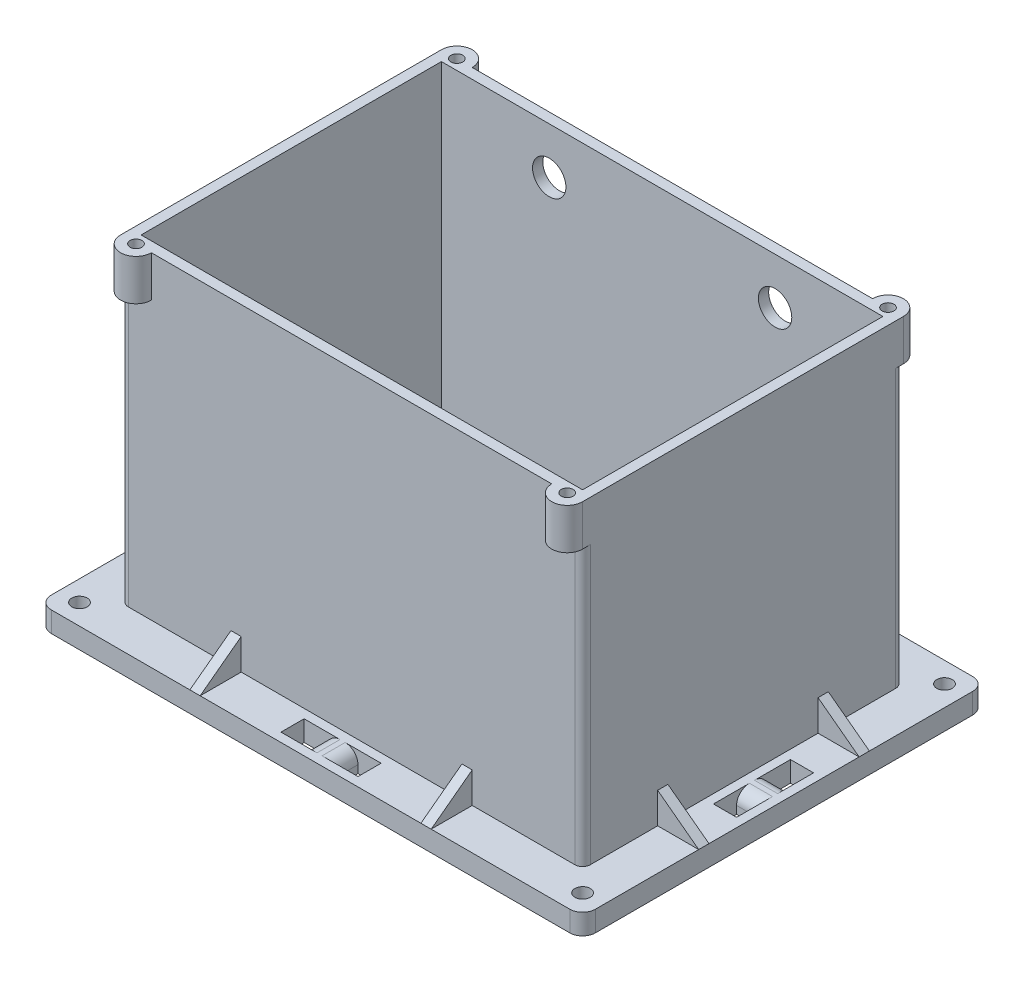
from build123d import *

# Parameters (mm, degrees)
BASE_W                                       = 90
BASE_H                                       = 62.5
BASE_EXTRUDE_DEPTH                           = 2
WALLS_W                                      = 90
WALLS_H                                      = 62.5
WALLS_W_2                                    = 86
WALLS_H_2                                    = 58.5
WALLS_EXTRUDE_DEPTH                          = 64
OUTJUT_EXTRUDE_DEPTH                         = 8
HOLES_R                                      = 1.15
HOLES_CUT_DEPTH                              = 6
ANTENNA_GPS_HOLES_R                          = 3.25
ANTENNA_GPS_HOLES_CUT_DEPTH                  = 2
PAD_W                                        = 106
PAD_H                                        = 78.5
PAD_EXTRUDE_DEPTH                            = 4
SCREW_HOLES_R                                = 1.5
SCREW_HOLES_CUT_DEPTH                        = 5
WALL_FILLETS_R                               = 1.5
LENGTH_SUPPORTS_EXTRUDE_DEPTH                = 1
LENGTH_SUPPORT_EXTRUDE_OPPOSING_MIRR_2_DEPTH = 1
WIDTH_SUPPORTS_EXTRUDE_DEPTH                 = 1
WIDTH_SUPPORTS_EXTRUDE_OPPOSING_MIRR_2_DEPTH = 1
ZIP_TIE_HOLE_W                               = 4.5
ZIP_TIE_HOLE_H                               = 4.5
ZIP_TIE_HOLE_LENGTH_CUT_DEPTH                = 5
ZIP_TIE_HOLE_LENGTH_OPPOSING_MIRROR_COPY_W   = 4.5
ZIP_TIE_HOLE_LENGTH_OPPOSING_MIRROR_COPY_H   = 4.5
ZIP_TIE_HOLE_LENGTH_OPPOSING_MIRROR_2_DEPTH  = 5
ZIP_TIE_HOLE_WIDTH_W                         = 4.5
ZIP_TIE_HOLE_WIDTH_H                         = 4.5
ZIP_TIE_HOLE_WIDTH_CUT_DEPTH                 = 5
ZIP_TIE_HOLE_WIDTH_OPPOSING_MIRROR_COPY_W    = 4.5
ZIP_TIE_HOLE_WIDTH_OPPOSING_MIRROR_COPY_H    = 4.5
ZIP_TIE_HOLE_WIDTH_OPPOSING_MIRROR_C_2_DEPTH = 5
ZIP_TIE_FILLETS_R                            = 2.5
PAD_FILLETS_R                                = 2.5


with BuildPart() as part:
    # Base → Base Extrude (new body)
    with BuildSketch(Plane(origin=(0, 0, 0), x_dir=(1, 0, 0), z_dir=(0, 1, 0))):
        with Locations((45, 31.25)):
            Rectangle(BASE_W, BASE_H)
    extrude(amount=BASE_EXTRUDE_DEPTH)

    # Walls → Walls Extrude (add)
    with BuildSketch(Plane(origin=(0, 2, 0), x_dir=(1, 0, 0), z_dir=(0, 1, 0))):
        with Locations((45, 31.25)):
            Rectangle(WALLS_W, WALLS_H)
        with Locations((45, 31.25)):
            Rectangle(WALLS_W_2, WALLS_H_2, mode=Mode.SUBTRACT)
    extrude(amount=WALLS_EXTRUDE_DEPTH)

    # Outjut → Outjut Extrude (add)
    with BuildSketch(Plane(origin=(0, 66, 0), x_dir=(1, 0, 0), z_dir=(0, 1, 0))):
        with BuildLine():
            Line((0, 62.5), (6, 62.5))
            ThreePointArc((6, 62.5), (3, 65.5), (0, 62.5))
        make_face()
        with BuildLine():
            Line((90, 62.5), (84, 62.5))
            ThreePointArc((84, 62.5), (87, 65.5), (90, 62.5))
        make_face()
        with BuildLine():
            Line((90, 0), (84, 0))
            ThreePointArc((84, 0), (87, -3), (90, 0))
        make_face()
        with BuildLine():
            Line((0, 0), (6, 0))
            ThreePointArc((6, 0), (3, -3), (0, 0))
        make_face()
    extrude(amount=-OUTJUT_EXTRUDE_DEPTH)

    # Holes → Holes Cut (cut)
    with BuildSketch(Plane(origin=(0, 66, 0), x_dir=(1, 0, 0), z_dir=(0, 1, 0))):
        with Locations((3, 62.5)):
            Circle(HOLES_R)
        with Locations((87, 62.5)):
            Circle(HOLES_R)
        with Locations((87, 0)):
            Circle(HOLES_R)
        with Locations((3, 0)):
            Circle(HOLES_R)
    extrude(amount=-HOLES_CUT_DEPTH, mode=Mode.SUBTRACT)

    # Antenna/GPS Holes → Antenna/GPS Holes Cut (cut)
    with BuildSketch(Plane(origin=(0, 0, -62.5), x_dir=(-1, 0, 0), z_dir=(0, 0, -1))):
        with Locations((-23, 56.95)):
            Circle(ANTENNA_GPS_HOLES_R)
        with Locations((-67, 56.95)):
            Circle(ANTENNA_GPS_HOLES_R)
    extrude(amount=-ANTENNA_GPS_HOLES_CUT_DEPTH, mode=Mode.SUBTRACT)

    # Pad → Pad Extrude (add)
    with BuildSketch(Plane.XZ):
        with Locations((45, -31.25)):
            Rectangle(PAD_W, PAD_H)
    extrude(amount=-PAD_EXTRUDE_DEPTH)

    # Screw Holes → Screw Holes Cut (cut, through all)
    with BuildSketch(Plane(origin=(0, 4, 0), x_dir=(1, 0, 0), z_dir=(0, 1, 0))):
        with Locations((94, 66.5)):
            Circle(SCREW_HOLES_R)
        with Locations((-4, 66.5)):
            Circle(SCREW_HOLES_R)
        with Locations((94, -4)):
            Circle(SCREW_HOLES_R)
        with Locations((-4, -4)):
            Circle(SCREW_HOLES_R)
    extrude(amount=-SCREW_HOLES_CUT_DEPTH, mode=Mode.SUBTRACT)

    # Wall Fillets
    wall_fillets_edges = [part.edges().sort_by_distance(p)[0] for p in [
        (0, 31, 0),
        (0, 31, -62.5),
        (90, 31, -62.5),
        (90, 31, 0),
    ]]
    fillet(wall_fillets_edges, radius=WALL_FILLETS_R)

    # Length Supports → Length Supports Extrude (add, symmetric)
    with BuildSketch(Plane(origin=(22.5, 0, 0), x_dir=(0, 0, -1), z_dir=(1, 0, 0))):
        Polygon((0, 4), (-8, 4), (0, 10), align=None)
    length_supports_extrude = extrude(amount=LENGTH_SUPPORTS_EXTRUDE_DEPTH, both=True)

    # Length Support Extrude Mirror: Length Supports Extrude across plane
    add(length_supports_extrude.mirror(Plane(origin=(45, 0, 0), x_dir=(0, 0, 1), z_dir=(1, 0, 0))))

    # Length Support Extrude Opposing Mirror: Length Supports Extrude across plane
    add(length_supports_extrude.mirror(Plane.XY.offset(-31.25)))

    # Length Support Extrude Opposing Mirror c → Length Support Extrude Opposing Mirr 2 (add, symmetric)
    with BuildSketch(Plane(origin=(67.5, 0, -62.5), x_dir=(0, 0, 1), z_dir=(-1, 0, 0))):
        Polygon((0, 4), (-8, 4), (0, 10), align=None)
    extrude(amount=LENGTH_SUPPORT_EXTRUDE_OPPOSING_MIRR_2_DEPTH, both=True)

    # Width Supports → Width Supports Extrude (add, symmetric)
    with BuildSketch(Plane.XY.offset(-15.625)):
        Polygon((0, 4), (-8, 4), (0, 10), align=None)
    width_supports_extrude = extrude(amount=WIDTH_SUPPORTS_EXTRUDE_DEPTH, both=True)

    # Width Supports Extrude Mirror: Width Supports Extrude across plane
    add(width_supports_extrude.mirror(Plane.XY.offset(-31.25)))

    # Width Supports Extrude Opposing Mirror: Width Supports Extrude across plane
    add(width_supports_extrude.mirror(Plane(origin=(45, 0, 0), x_dir=(0, 0, 1), z_dir=(1, 0, 0))))

    # Width Supports Extrude Opposing Mirror c → Width Supports Extrude Opposing Mirr 2 (add, symmetric)
    with BuildSketch(Plane(origin=(90, 0, -46.875), x_dir=(-1, 0, 0), z_dir=(0, 0, -1))):
        Polygon((0, 4), (-8, 4), (0, 10), align=None)
    extrude(amount=WIDTH_SUPPORTS_EXTRUDE_OPPOSING_MIRR_2_DEPTH, both=True)

    # Zip Tie Hole → Zip Tie Hole Length Cut (cut, through all)
    with BuildSketch(Plane(origin=(0, 4, 0), x_dir=(1, 0, 0), z_dir=(0, 1, 0))):
        with Locations((39.75, -4)):
            Rectangle(ZIP_TIE_HOLE_W, ZIP_TIE_HOLE_H)
    zip_tie_hole_length_cut = extrude(amount=-ZIP_TIE_HOLE_LENGTH_CUT_DEPTH, mode=Mode.SUBTRACT)

    # Zip Tie Hole Length Mirror: Zip Tie Hole Length Cut across plane
    add(zip_tie_hole_length_cut.mirror(Plane(origin=(45, 0, 0), x_dir=(0, 0, 1), z_dir=(1, 0, 0))), mode=Mode.SUBTRACT)

    # Zip Tie Hole Length Opposing Mirror: Zip Tie Hole Length Cut across plane
    add(zip_tie_hole_length_cut.mirror(Plane.XY.offset(-31.25)), mode=Mode.SUBTRACT)

    # Zip Tie Hole Length Opposing Mirror copy → Zip Tie Hole Length Opposing Mirror  2 (cut, through all)
    with BuildSketch(Plane(origin=(90, 4, -62.5), x_dir=(-1, 0, 0), z_dir=(0, 1, 0))):
        with Locations((39.75, -4)):
            Rectangle(ZIP_TIE_HOLE_LENGTH_OPPOSING_MIRROR_COPY_W, ZIP_TIE_HOLE_LENGTH_OPPOSING_MIRROR_COPY_H)
    extrude(amount=-ZIP_TIE_HOLE_LENGTH_OPPOSING_MIRROR_2_DEPTH, mode=Mode.SUBTRACT)

    # Zip Tie Hole Width → Zip Tie Hole Width Cut (cut, through all)
    with BuildSketch(Plane(origin=(0, 4, 0), x_dir=(1, 0, 0), z_dir=(0, 1, 0))):
        with Locations((-4, 36.5)):
            Rectangle(ZIP_TIE_HOLE_WIDTH_W, ZIP_TIE_HOLE_WIDTH_H)
    zip_tie_hole_width_cut = extrude(amount=-ZIP_TIE_HOLE_WIDTH_CUT_DEPTH, mode=Mode.SUBTRACT)

    # Zip Tie Hole Width Mirror: Zip Tie Hole Width Cut across plane
    add(zip_tie_hole_width_cut.mirror(Plane.XY.offset(-31.25)), mode=Mode.SUBTRACT)

    # Zip Tie Hole Width Opposing Mirror: Zip Tie Hole Width Cut across plane
    add(zip_tie_hole_width_cut.mirror(Plane(origin=(45, 0, 0), x_dir=(0, 0, 1), z_dir=(1, 0, 0))), mode=Mode.SUBTRACT)

    # Zip Tie Hole Width Opposing Mirror copy → Zip Tie Hole Width Opposing Mirror c 2 (cut, through all)
    with BuildSketch(Plane(origin=(90, 4, -62.5), x_dir=(-1, 0, 0), z_dir=(0, 1, 0))):
        with Locations((-4, 36.5)):
            Rectangle(ZIP_TIE_HOLE_WIDTH_OPPOSING_MIRROR_COPY_W, ZIP_TIE_HOLE_WIDTH_OPPOSING_MIRROR_COPY_H)
    extrude(amount=-ZIP_TIE_HOLE_WIDTH_OPPOSING_MIRROR_C_2_DEPTH, mode=Mode.SUBTRACT)

    # Zip Tie Fillets
    zip_tie_fillets_edges = [part.edges().sort_by_distance(p)[0] for p in [
        (42, 4, 4),
        (48, 4, 4),
        (42, 4, -66.5),
        (48, 4, -66.5),
        (-4, 4, -34.25),
        (-4, 4, -28.25),
        (94, 4, -34.25),
        (94, 4, -28.25),
    ]]
    fillet(zip_tie_fillets_edges, radius=ZIP_TIE_FILLETS_R)

    # Pad Fillets
    pad_fillets_edges = [part.edges().sort_by_distance(p)[0] for p in [
        (-8, 2, -70.5),
        (-8, 2, 8),
        (98, 2, 8),
        (98, 2, -70.5),
    ]]
    fillet(pad_fillets_edges, radius=PAD_FILLETS_R)


solid = part.part
